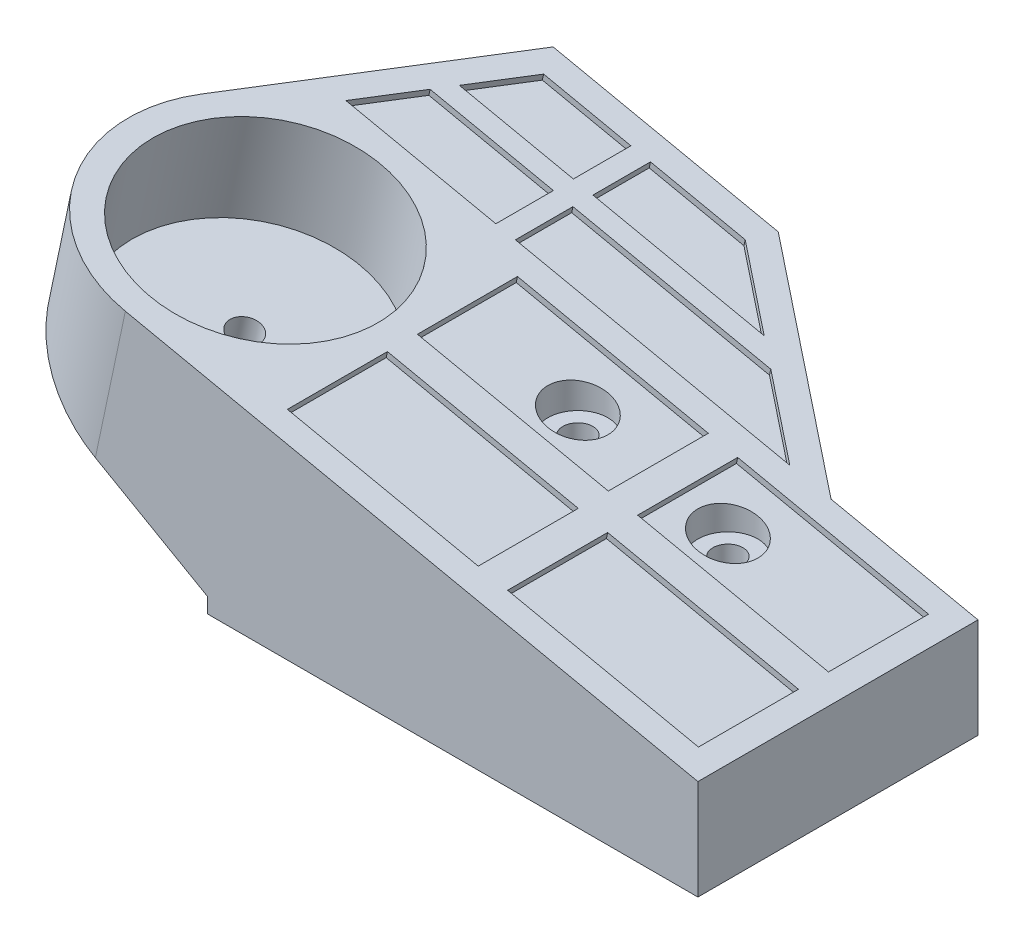
from build123d import *

# Parameters (mm, degrees)
BOSS_EXTRUDE1_DEPTH     = 28
BOSS_EXTRUDE2_DEPTH     = 10
CUT_EXTRUDE1_DEPTH      = 15.675439909
CUT_EXTRUDE1_DEPTH_BACK = 25.887131558
SKETCH3_R               = 11.5
CUT_EXTRUDE2_DEPTH      = 10
SKETCH4_R               = 1.5
CUT_EXTRUDE3_DEPTH      = 26
SKETCH5_W               = 19.5
SKETCH5_H               = 10
SKETCH5_RX              = 1.533173802
SKETCH5_RY              = 1.5
CUT_EXTRUDE4_DEPTH      = 0.6
CUT_EXTRUDE5_REACH      = 13
SKETCH6_R               = 3
CUT_EXTRUDE6_REACH      = 16
SKETCH7_R               = 3
CUT_EXTRUDE7_REACH      = 16.887
SKETCH8_R               = 1.5
CUT_EXTRUDE8_REACH      = 13.387
SKETCH9_R               = 3


with BuildPart() as part:
    # Sketch1 → Boss-Extrude1 (new body)
    with BuildSketch(Plane.XY):
        Polygon((0, 0), (49, 0), (49, 10), (-21.931026719, 25), (-24, 15.216373394), (0, 1.5), align=None)
    extrude(amount=BOSS_EXTRUDE1_DEPTH)

    # Sketch2 → Boss-Extrude2 (add)
    with BuildSketch(Plane(origin=(4.121724919, 19.490545356, 0), x_dir=(0.978362661, -0.206897328, 0), z_dir=(0.206897328, 0.978362661, 0))):
        Polygon((-13.893841917, 16), (-21.483308301, 0), (30.854721254, 0), (9.106158083, 16), align=None)
    extrude(amount=-BOSS_EXTRUDE2_DEPTH)

    # Sketch2_3 → Cut-Extrude1 (cut, two sides)
    with BuildSketch(Plane(origin=(4.121724919, 19.490545356, 0), x_dir=(0.978362661, -0.206897328, 0), z_dir=(0.206897328, 0.978362661, 0))) as cut_extrude1_sk:
        with BuildLine():
            ThreePointArc((-12.628930853, -28), (-22.528425788, -23.899494938), (-26.628930853, -14.000000004))
            Line((-26.628930853, -14.000000004), (-26.628930853, -28))
            Line((-26.628930853, -28), (-12.628930853, -28))
        make_face()
        with BuildLine():
            Line((-25.278041493, -8), (-21.483308301, 0))
            Line((-21.483308301, 0), (-26.628930853, 0))
            Line((-26.628930853, 0), (-26.628930853, -14.000000004))
            ThreePointArc((-26.628930853, -14.000000004), (-26.287033741, -10.924902359), (-25.278041493, -8))
        make_face()
    extrude(amount=CUT_EXTRUDE1_DEPTH, mode=Mode.SUBTRACT)
    extrude(cut_extrude1_sk.sketch, amount=-CUT_EXTRUDE1_DEPTH_BACK, mode=Mode.SUBTRACT)

    # Sketch3 → Cut-Extrude2 (cut)
    with BuildSketch(Plane(origin=(4.121724919, 19.490545356, 0), x_dir=(0.978362661, -0.206897328, 0), z_dir=(0.206897328, 0.978362661, 0))):
        with Locations((-12.628930853, -14)):
            Circle(SKETCH3_R)
    extrude(amount=-CUT_EXTRUDE2_DEPTH, mode=Mode.SUBTRACT)

    # Sketch4 → Cut-Extrude3 (cut, through all)
    with BuildSketch(Plane.XZ):
        with Locations((17, 8)):
            Circle(SKETCH4_R)
        with Locations((32, 8)):
            Circle(SKETCH4_R)
    extrude(amount=-CUT_EXTRUDE3_DEPTH, mode=Mode.SUBTRACT)

    # Sketch5 → Cut-Extrude4 (cut)
    with BuildSketch(Plane(origin=(4.121724919, 19.490545356, 0), x_dir=(0.978362661, -0.206897328, 0), z_dir=(0.206897328, 0.978362661, 0))):
        Polygon((-18.716315349, 0), (-3.393841917, 0), (-3.393841917, 5.75), (-15.988850867, 5.75), align=None)
        Polygon((-15.040167569, 7.75), (-3.393841917, 7.75), (-3.393841917, 13.5), (-12.312703087, 13.5), align=None)
        Polygon((-1.393841917, 7.75), (16.101510968, 7.75), (8.285621079, 13.5), (-1.393841917, 13.5), align=None)
        Polygon((20.870933117, 0), (23.870933117, 0), (26.635971254, 0), (18.820081364, 5.75), (-1.393841917, 5.75), (-1.393841917, 0), (1.370933117, 0), align=None)
        with Locations((11.120933117, -7.5)):
            Rectangle(SKETCH5_W, SKETCH5_H)
        with BuildLine():
            add(Edge.make_bspline(
                [(14.696263114, -8), (14.696263114, -5.401923789), (12.396502412, -6.700961894), (10.096741709, -8), (12.396502412, -9.299038106), (14.696263114, -10.598076211), (14.696263114, -8)],
                knots=[0, 0, 0, 2.094395102, 2.094395102, 4.188790205, 4.188790205, 6.283185307, 6.283185307, 6.283185307], degree=2, weights=[1, 0.5, 1, 0.5, 1, 0.5, 1]))
        make_face(mode=Mode.SUBTRACT)
        with Locations((11.120933117, -20.5)):
            Rectangle(SKETCH5_W, SKETCH5_H)
        with Locations((33.620933117, -20.5)):
            Rectangle(SKETCH5_W, SKETCH5_H)
        with Locations((33.620933117, -7.5)):
            Rectangle(SKETCH5_W, SKETCH5_H)
        with BuildLine():
            add(Edge.make_bspline(
                [(30.028001134, -8), (30.028001134, -5.401923789), (27.728240431, -6.700961894), (25.428479728, -8), (27.728240431, -9.299038106), (30.028001134, -10.598076211), (30.028001134, -8)],
                knots=[0, 0, 0, 2.094395102, 2.094395102, 4.188790205, 4.188790205, 6.283185307, 6.283185307, 6.283185307], degree=2, weights=[1, 0.5, 1, 0.5, 1, 0.5, 1]))
        make_face(mode=Mode.SUBTRACT)
        with Locations((13.163089313, -8)):
            Ellipse(SKETCH5_RX, SKETCH5_RY)
        with Locations((28.494827332, -8)):
            Ellipse(SKETCH5_RX, SKETCH5_RY)
    extrude(amount=-CUT_EXTRUDE4_DEPTH, mode=Mode.SUBTRACT)

    # Sketch6 → Cut-Extrude5 (cut, up to next)
    with BuildSketch(Plane(origin=(0, 14, 0), x_dir=(-1, 0, 0), z_dir=(0, -1, 0)), mode=Mode.PRIVATE) as cut_extrude5_sk1:
        with Locations((-17, -8)):
            Circle(SKETCH6_R)
    cut_extrude5_tool1 = extrude(cut_extrude5_sk1.sketch, amount=-CUT_EXTRUDE5_REACH, mode=Mode.PRIVATE) & part.part
    add(cut_extrude5_tool1.solids().sort_by_distance((17, 14, 8))[0], mode=Mode.SUBTRACT)

    # Sketch7 → Cut-Extrude6 (cut, up to next)
    with BuildSketch(Plane(origin=(0, 11, 0), x_dir=(-1, 0, 0), z_dir=(0, -1, 0)), mode=Mode.PRIVATE) as cut_extrude6_sk1:
        with Locations((-32, -8)):
            Circle(SKETCH7_R)
    cut_extrude6_tool1 = extrude(cut_extrude6_sk1.sketch, amount=-CUT_EXTRUDE6_REACH, mode=Mode.PRIVATE) & part.part
    add(cut_extrude6_tool1.solids().sort_by_distance((32, 11, 8))[0], mode=Mode.SUBTRACT)

    # Sketch8 → Cut-Extrude7 (cut, up to next)
    with BuildSketch(Plane(origin=(2.052751638, 9.70691875, 0), x_dir=(0.978362661, -0.206897328, 0), z_dir=(0.206897328, 0.978362661, 0)), mode=Mode.PRIVATE) as cut_extrude7_sk1:
        with Locations((-12.628930853, -14)):
            Circle(SKETCH8_R)
    cut_extrude7_tool1 = extrude(cut_extrude7_sk1.sketch, amount=-CUT_EXTRUDE7_REACH, mode=Mode.PRIVATE) & part.part
    add(cut_extrude7_tool1.solids().sort_by_distance((-10.302923, 12.319811, 14))[0], mode=Mode.SUBTRACT)

    # Sketch9 → Cut-Extrude8 (cut, up to next)
    with BuildSketch(Plane(origin=(1.328610989, 6.282649438, 0), x_dir=(0.978362661, -0.206897328, 0), z_dir=(0.206897328, 0.978362661, 0)), mode=Mode.PRIVATE) as cut_extrude8_sk1:
        with Locations((-12.628930853, -14)):
            Circle(SKETCH9_R)
    cut_extrude8_tool1 = extrude(cut_extrude8_sk1.sketch, amount=-CUT_EXTRUDE8_REACH, mode=Mode.PRIVATE) & part.part
    add(cut_extrude8_tool1.solids().sort_by_distance((-11.027063, 8.895541, 14))[0], mode=Mode.SUBTRACT)


solid = part.part
